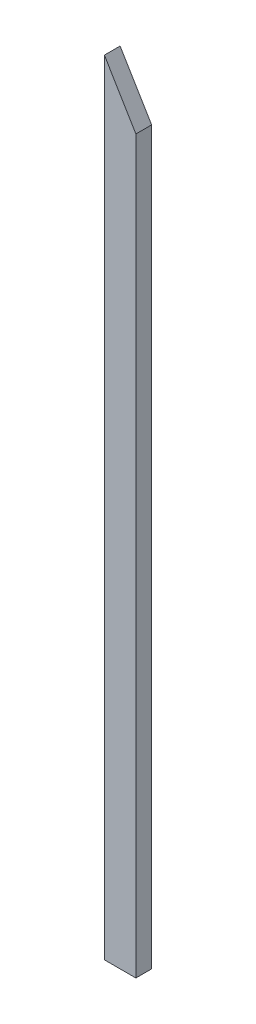
from build123d import *

# Parameters (mm, degrees)
SKETCH1_W           = 38.1
SKETCH1_H           = 948.6646
BOSS_EXTRUDE1_DEPTH = 19.05
CUT_EXTRUDE1_DEPTH  = 20.05


with BuildPart() as part:
    # Sketch1 → Boss-Extrude1 (new body)
    with BuildSketch(Plane.XY):
        with Locations((-46.17069125, -96.560503929)):
            Rectangle(SKETCH1_W, SKETCH1_H)
    extrude(amount=BOSS_EXTRUDE1_DEPTH)

    # Sketch2 → Cut-Extrude1 (cut, through all)
    with BuildSketch(Plane.XY.offset(19.05)):
        Polygon((-65.22069125, 377.771796071), (-27.12069125, 314.111334956), (-27.12069125, 377.771796071), align=None)
    extrude(amount=-CUT_EXTRUDE1_DEPTH, mode=Mode.SUBTRACT)


solid = part.part
